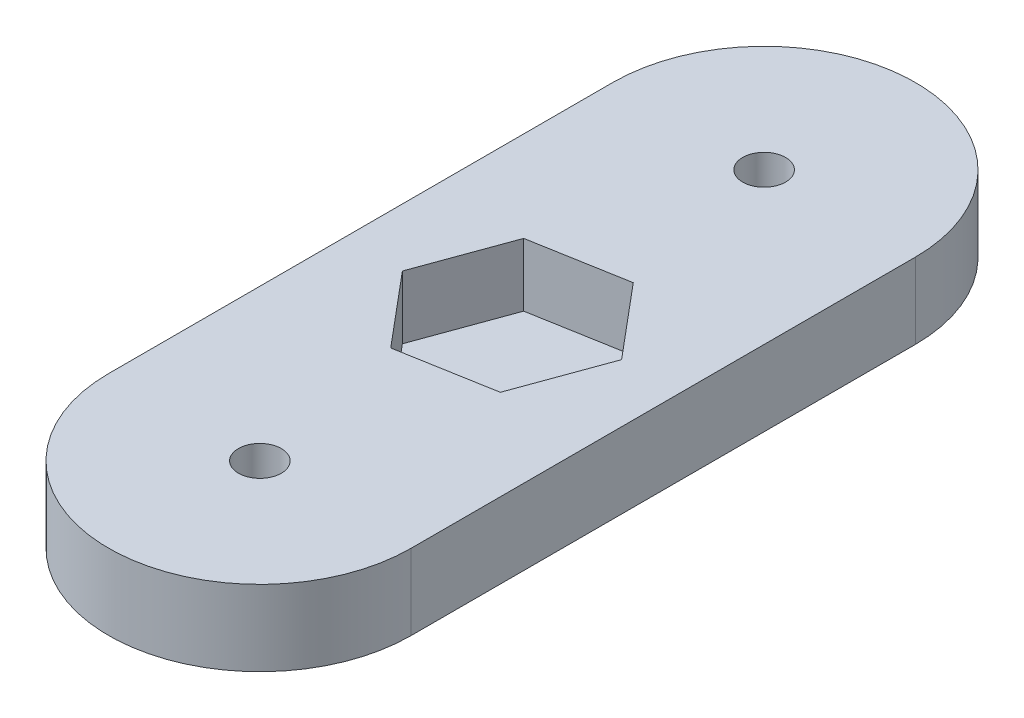
from build123d import *

# Parameters (mm, degrees)
SKETCH1_R           = 1.7
BOSS_EXTRUDE1_DEPTH = 6
CUT_EXTRUDE1_DEPTH  = 5


with BuildPart() as part:
    # Sketch1 → Boss-Extrude1 (new body)
    with BuildSketch(Plane(origin=(0, 0, 0), x_dir=(1, 0, 0), z_dir=(0, 1, 0))):
        with BuildLine():
            Line((-12, 0), (-12, 40))
            ThreePointArc((-12, 40), (0, 52), (12, 40))
            Line((12, 40), (12, 0))
            ThreePointArc((12, 0), (0, -12), (-12, 0))
        make_face()
        with Locations((0, 40)):
            Circle(SKETCH1_R, mode=Mode.SUBTRACT)
        Circle(SKETCH1_R, mode=Mode.SUBTRACT)
    extrude(amount=BOSS_EXTRUDE1_DEPTH)

    # Sketch2 → Cut-Extrude1 (cut)
    with BuildSketch(Plane(origin=(0, 6, 0), x_dir=(1, 0, 0), z_dir=(0, 1, 0))):
        Polygon((4.824476793, 14.250412449), (7.391527277, 21.303325688), (2.567050484, 27.052913238), (-4.824476793, 25.749587551), (-7.391527277, 18.696674312), (-2.567050484, 12.947086762), align=None)
    extrude(amount=-CUT_EXTRUDE1_DEPTH, mode=Mode.SUBTRACT)


solid = part.part
